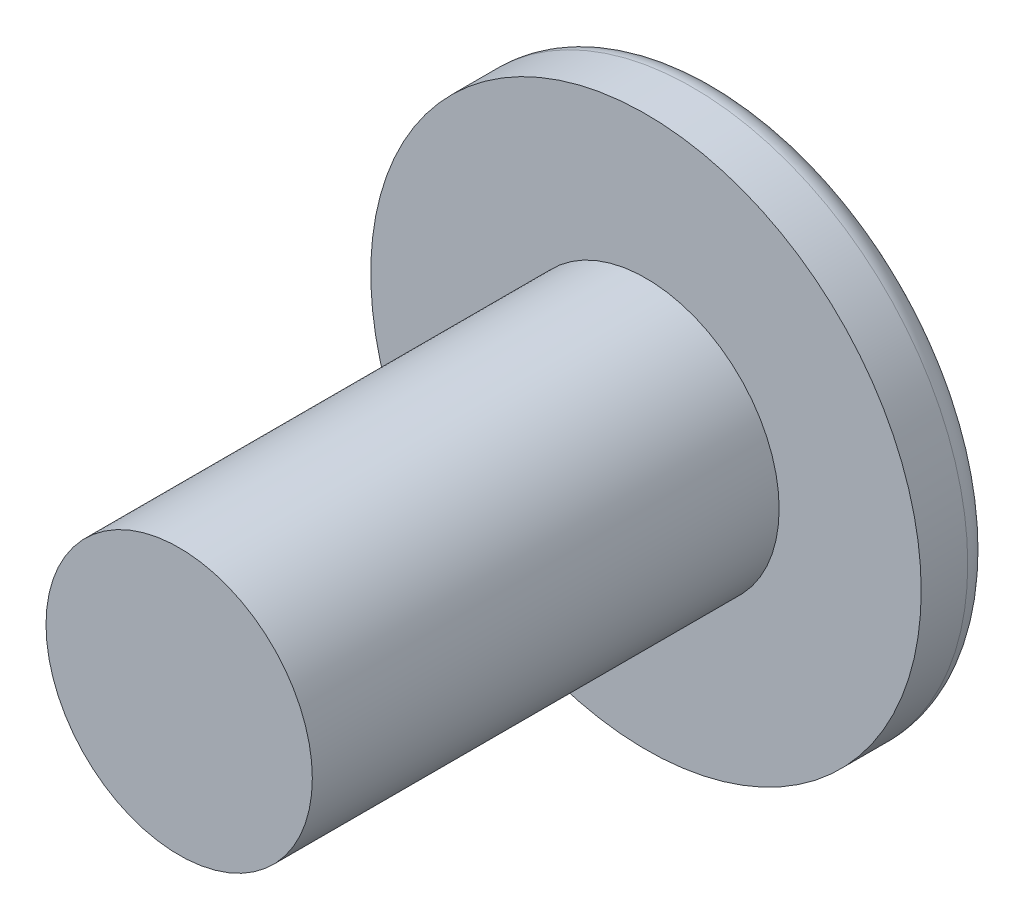
from build123d import *

# Parameters (mm, degrees)
SKETCH1_R           = 5.56
BOSS_EXTRUDE1_DEPTH = 1.44
SKETCH2_R           = 2.69
BOSS_EXTRUDE2_DEPTH = 9.43
FILLET1_R           = 0.5


with BuildPart() as part:
    # Sketch1 → Boss-Extrude1 (new body)
    with BuildSketch(Plane.XY):
        Circle(SKETCH1_R)
    extrude(amount=BOSS_EXTRUDE1_DEPTH)

    # Sketch2 → Boss-Extrude2 (add)
    with BuildSketch(Plane.XY.offset(1.44)):
        Circle(SKETCH2_R)
    extrude(amount=BOSS_EXTRUDE2_DEPTH)

    # Fillet1
    fillet1_edges = [part.edges().sort_by_distance(p)[0] for p in [
        (-5.56, 0, 0),
    ]]
    fillet(fillet1_edges, radius=FILLET1_R)


solid = part.part
